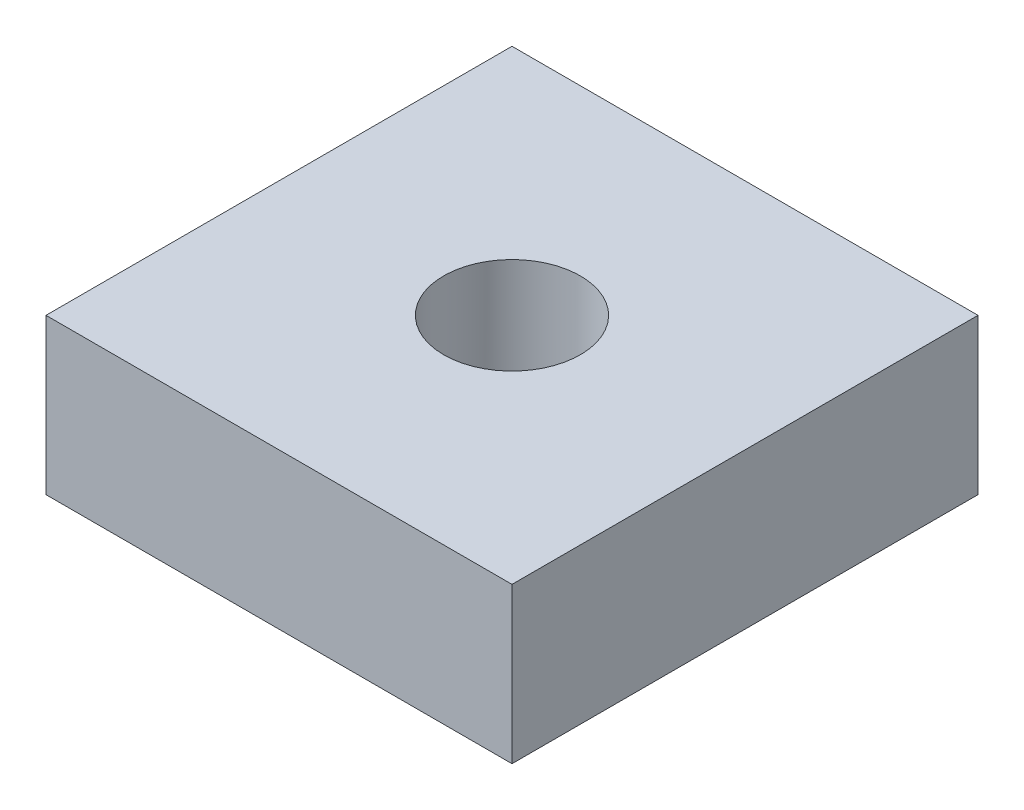
from build123d import *

# Parameters (mm, degrees)
SKETCH1_W           = 38.1
SKETCH1_H           = 38.1
BOSS_EXTRUDE1_DEPTH = 12.7
CUT_EXTRUDE1_REACH  = 14.7
SKETCH2_R           = 5.588


with BuildPart() as part:
    # Sketch1 → Boss-Extrude1 (new body)
    with BuildSketch(Plane(origin=(0, 0, 0), x_dir=(1, 0, 0), z_dir=(0, 1, 0))):
        Rectangle(SKETCH1_W, SKETCH1_H)
    extrude(amount=BOSS_EXTRUDE1_DEPTH)

    # Sketch2 → Cut-Extrude1 (cut, up to next)
    with BuildSketch(Plane(origin=(0, 12.7, 0), x_dir=(1, 0, 0), z_dir=(0, 1, 0)), mode=Mode.PRIVATE) as cut_extrude1_sk1:
        Circle(SKETCH2_R)
    cut_extrude1_tool1 = extrude(cut_extrude1_sk1.sketch, amount=-CUT_EXTRUDE1_REACH, mode=Mode.PRIVATE) & part.part
    add(cut_extrude1_tool1.solids().sort_by_distance((0, 12.7, 0))[0], mode=Mode.SUBTRACT)


solid = part.part
